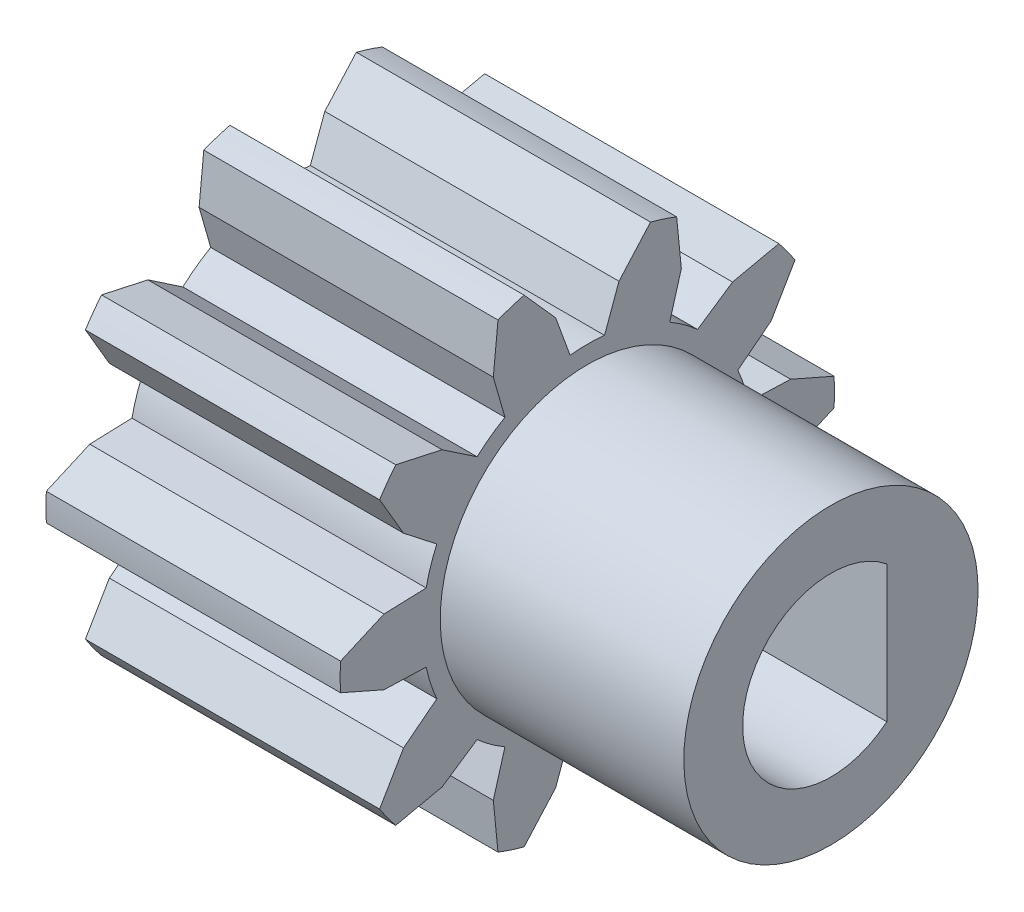
from build123d import *

# Parameters (mm, degrees)
ESQUISSE1_W              = 5
ESQUISSE1_H              = 4.2
ENL_V_MAT_EXTRU_1_DEPTH  = 6
ENL_V_MAT_EXTRU_2_DEPTH  = 6
ENL_V_MAT_EXTRU_3_DEPTH  = 6
ENL_V_MAT_EXTRU_4_DEPTH  = 6
ENL_V_MAT_EXTRU_5_DEPTH  = 6
ENL_V_MAT_EXTRU_6_DEPTH  = 6
ENL_V_MAT_EXTRU_7_DEPTH  = 6
ENL_V_MAT_EXTRU_8_DEPTH  = 6
ENL_V_MAT_EXTRU_9_DEPTH  = 6
ENL_V_MAT_EXTRU_10_DEPTH = 6
ENL_V_MAT_EXTRU_11_DEPTH = 6
ENL_V_MAT_EXTRU_12_DEPTH = 6
ENL_V_MAT_EXTRU_13_DEPTH = 6
ENL_V_MAT_EXTRU_14_DEPTH = 6
ENL_V_MAT_EXTRU_15_DEPTH = 6
ENL_V_MAT_EXTRU_16_DEPTH = 6
ENL_V_MAT_EXTRU_17_DEPTH = 6
ENL_V_MAT_EXTRU_18_DEPTH = 6
ENL_V_MAT_EXTRU_19_DEPTH = 6
ENL_V_MAT_EXTRU_20_DEPTH = 6
ESQUISSE22_W             = 4.14
ESQUISSE22_H             = 2.5
ESQUISSE29_R             = 1.5
ENL_V_MAT_EXTRU_21_DEPTH = 10
BOSS_EXTRU_1_DEPTH       = 9.14


with BuildPart() as part:
    # Esquisse1 → Révolution1 (revolve)
    with BuildSketch(Plane(origin=(0, 0, 0), x_dir=(-1, 0, 0), z_dir=(0, 0, -1))):
        with Locations((0, 2.1)):
            Rectangle(ESQUISSE1_W, ESQUISSE1_H)
    revolve(axis=Axis((2.5, 0, 0), (-1, 0, 0)))

    # Esquisse2 → Enlèv. mat.-Extru.1 (cut, through all)
    with BuildSketch(Plane.ZY.offset(2.5)):
        with BuildLine():
            Line((4.19351351, -0.233333333), (2.714671649, -0.882050288))
            Line((2.714671649, -0.882050288), (3.529773588, -2.276114764))
            ThreePointArc((3.529773588, -2.276114764), (3.994437368, -1.297871376), (4.19351351, -0.233333333))
        make_face()
    extrude(amount=-ENL_V_MAT_EXTRU_1_DEPTH, mode=Mode.SUBTRACT)

    # Esquisse3 → Enlèv. mat.-Extru.2 (cut, through all)
    with BuildSketch(Plane.ZY.offset(2.5)):
        with BuildLine():
            Line((2.557927281, -1.138862601), (3.122928651, -1.58029005))
            Line((3.122928651, -1.58029005), (2.714671649, -0.882050288))
            Line((2.714671649, -0.882050288), (3.455373536, -0.557129899))
            Line((3.455373536, -0.557129899), (2.738813282, -0.582152734))
            ThreePointArc((2.738813282, -0.582152734), (2.662958246, -0.865247584), (2.557927281, -1.138862601))
        make_face()
    extrude(amount=-ENL_V_MAT_EXTRU_2_DEPTH, mode=Mode.SUBTRACT)

    # Esquisse4 → Enlèv. mat.-Extru.3 (cut, through all)
    with BuildSketch(Plane.ZY.offset(2.5)):
        with BuildLine():
            Line((3.255473803, -2.653656028), (1.677759348, -2.309237633))
            Line((1.677759348, -2.309237633), (1.517780128, -3.916164384))
            ThreePointArc((1.517780128, -3.916164384), (2.46869806, -3.397871376), (3.255473803, -2.653656028))
        make_face()
    extrude(amount=-ENL_V_MAT_EXTRU_3_DEPTH, mode=Mode.SUBTRACT)

    # Esquisse5 → Enlèv. mat.-Extru.4 (cut, through all)
    with BuildSketch(Plane.ZY.offset(2.5)):
        with BuildLine():
            Line((1.4, -2.424871131), (1.597631165, -3.114092911))
            Line((1.597631165, -3.114092911), (1.677759348, -2.309237633))
            Line((1.677759348, -2.309237633), (2.467983175, -2.481745162))
            Line((2.467983175, -2.481745162), (1.873565698, -2.080805511))
            ThreePointArc((1.873565698, -2.080805511), (1.645798706, -2.265247584), (1.4, -2.424871131))
        make_face()
    extrude(amount=-ENL_V_MAT_EXTRU_4_DEPTH, mode=Mode.SUBTRACT)

    # Esquisse6 → Enlèv. mat.-Extru.5 (cut, through all)
    with BuildSketch(Plane.ZY.offset(2.5)):
        with BuildLine():
            Line((1.073953753, -4.060372315), (0, -2.85437469))
            Line((0, -2.85437469), (-1.073953753, -4.060372315))
            ThreePointArc((-1.073953753, -4.060372315), (0, -4.2), (1.073953753, -4.060372315))
        make_face()
    extrude(amount=-ENL_V_MAT_EXTRU_5_DEPTH, mode=Mode.SUBTRACT)

    # Esquisse7 → Enlèv. mat.-Extru.6 (cut, through all)
    with BuildSketch(Plane.ZY.offset(2.5)):
        with BuildLine():
            Line((-0.292679697, -2.784661307), (-0.537907124, -3.458418125))
            Line((-0.537907124, -3.458418125), (0, -2.85437469))
            Line((0, -2.85437469), (0.537907124, -3.458418125))
            Line((0.537907124, -3.458418125), (0.292679697, -2.784661307))
            ThreePointArc((0.292679697, -2.784661307), (0, -2.8), (-0.292679697, -2.784661307))
        make_face()
    extrude(amount=-ENL_V_MAT_EXTRU_6_DEPTH, mode=Mode.SUBTRACT)

    # Esquisse8 → Enlèv. mat.-Extru.7 (cut, through all)
    with BuildSketch(Plane.ZY.offset(2.5)):
        with BuildLine():
            Line((-1.517780128, -3.916164384), (-1.677759348, -2.309237633))
            Line((-1.677759348, -2.309237633), (-3.255473803, -2.653656028))
            ThreePointArc((-3.255473803, -2.653656028), (-2.46869806, -3.397871376), (-1.517780128, -3.916164384))
        make_face()
    extrude(amount=-ENL_V_MAT_EXTRU_7_DEPTH, mode=Mode.SUBTRACT)

    # Esquisse9 → Enlèv. mat.-Extru.8 (cut, through all)
    with BuildSketch(Plane.ZY.offset(2.5)):
        with BuildLine():
            Line((-1.873565698, -2.080805511), (-2.467983175, -2.481745162))
            Line((-2.467983175, -2.481745162), (-1.677759348, -2.309237633))
            Line((-1.677759348, -2.309237633), (-1.597631165, -3.114092911))
            Line((-1.597631165, -3.114092911), (-1.4, -2.424871131))
            ThreePointArc((-1.4, -2.424871131), (-1.645798706, -2.265247584), (-1.873565698, -2.080805511))
        make_face()
    extrude(amount=-ENL_V_MAT_EXTRU_8_DEPTH, mode=Mode.SUBTRACT)

    # Esquisse10 → Enlèv. mat.-Extru.9 (cut, through all)
    with BuildSketch(Plane.ZY.offset(2.5)):
        with BuildLine():
            Line((-3.529773588, -2.276114764), (-2.714671649, -0.882050288))
            Line((-2.714671649, -0.882050288), (-4.19351351, -0.233333333))
            ThreePointArc((-4.19351351, -0.233333333), (-3.994437368, -1.297871376), (-3.529773588, -2.276114764))
        make_face()
    extrude(amount=-ENL_V_MAT_EXTRU_9_DEPTH, mode=Mode.SUBTRACT)

    # Esquisse11 → Enlèv. mat.-Extru.10 (cut, through all)
    with BuildSketch(Plane.ZY.offset(2.5)):
        with BuildLine():
            Line((-2.738813282, -0.582152734), (-3.455373536, -0.557129899))
            Line((-3.455373536, -0.557129899), (-2.714671649, -0.882050288))
            Line((-2.714671649, -0.882050288), (-3.122928651, -1.58029005))
            Line((-3.122928651, -1.58029005), (-2.557927281, -1.138862601))
            ThreePointArc((-2.557927281, -1.138862601), (-2.662958246, -0.865247584), (-2.738813282, -0.582152734))
        make_face()
    extrude(amount=-ENL_V_MAT_EXTRU_10_DEPTH, mode=Mode.SUBTRACT)

    # Esquisse12 → Enlèv. mat.-Extru.11 (cut, through all)
    with BuildSketch(Plane.ZY.offset(2.5)):
        with BuildLine():
            Line((-4.19351351, 0.233333333), (-2.714671649, 0.882050288))
            Line((-2.714671649, 0.882050288), (-3.529773588, 2.276114764))
            ThreePointArc((-3.529773588, 2.276114764), (-3.994437368, 1.297871376), (-4.19351351, 0.233333333))
        make_face()
    extrude(amount=-ENL_V_MAT_EXTRU_11_DEPTH, mode=Mode.SUBTRACT)

    # Esquisse13 → Enlèv. mat.-Extru.12 (cut, through all)
    with BuildSketch(Plane.ZY.offset(2.5)):
        with BuildLine():
            Line((-2.714671649, 0.882050288), (-3.455373536, 0.557129899))
            Line((-3.455373536, 0.557129899), (-2.738813282, 0.582152734))
            ThreePointArc((-2.738813282, 0.582152734), (-2.662958246, 0.865247584), (-2.557927281, 1.138862601))
            Line((-2.557927281, 1.138862601), (-3.122928651, 1.58029005))
            Line((-3.122928651, 1.58029005), (-2.714671649, 0.882050288))
        make_face()
    extrude(amount=-ENL_V_MAT_EXTRU_12_DEPTH, mode=Mode.SUBTRACT)

    # Esquisse14 → Enlèv. mat.-Extru.13 (cut, through all)
    with BuildSketch(Plane.ZY.offset(2.5)):
        with BuildLine():
            Line((-3.255473803, 2.653656028), (-1.677759348, 2.309237633))
            Line((-1.677759348, 2.309237633), (-1.517780128, 3.916164384))
            ThreePointArc((-1.517780128, 3.916164384), (-2.46869806, 3.397871376), (-3.255473803, 2.653656028))
        make_face()
    extrude(amount=-ENL_V_MAT_EXTRU_13_DEPTH, mode=Mode.SUBTRACT)

    # Esquisse15 → Enlèv. mat.-Extru.14 (cut, through all)
    with BuildSketch(Plane.ZY.offset(2.5)):
        with BuildLine():
            Line((-1.677759348, 2.309237633), (-2.467983175, 2.481745162))
            Line((-2.467983175, 2.481745162), (-1.873565698, 2.080805511))
            ThreePointArc((-1.873565698, 2.080805511), (-1.645798706, 2.265247584), (-1.4, 2.424871131))
            Line((-1.4, 2.424871131), (-1.597631165, 3.114092911))
            Line((-1.597631165, 3.114092911), (-1.677759348, 2.309237633))
        make_face()
    extrude(amount=-ENL_V_MAT_EXTRU_14_DEPTH, mode=Mode.SUBTRACT)

    # Esquisse16 → Enlèv. mat.-Extru.15 (cut, through all)
    with BuildSketch(Plane.ZY.offset(2.5)):
        with BuildLine():
            Line((-1.073953753, 4.060372315), (0, 2.85437469))
            Line((0, 2.85437469), (1.073953753, 4.060372315))
            ThreePointArc((1.073953753, 4.060372315), (0, 4.2), (-1.073953753, 4.060372315))
        make_face()
    extrude(amount=-ENL_V_MAT_EXTRU_15_DEPTH, mode=Mode.SUBTRACT)

    # Esquisse17 → Enlèv. mat.-Extru.16 (cut, through all)
    with BuildSketch(Plane.ZY.offset(2.5)):
        with BuildLine():
            Line((0, 2.85437469), (-0.537907124, 3.458418125))
            Line((-0.537907124, 3.458418125), (-0.292679697, 2.784661307))
            ThreePointArc((-0.292679697, 2.784661307), (0, 2.8), (0.292679697, 2.784661307))
            Line((0.292679697, 2.784661307), (0.537907124, 3.458418125))
            Line((0.537907124, 3.458418125), (0, 2.85437469))
        make_face()
    extrude(amount=-ENL_V_MAT_EXTRU_16_DEPTH, mode=Mode.SUBTRACT)

    # Esquisse18 → Enlèv. mat.-Extru.17 (cut, through all)
    with BuildSketch(Plane.ZY.offset(2.5)):
        with BuildLine():
            Line((1.517780128, 3.916164384), (1.677759348, 2.309237633))
            Line((1.677759348, 2.309237633), (3.255473803, 2.653656028))
            ThreePointArc((3.255473803, 2.653656028), (2.46869806, 3.397871376), (1.517780128, 3.916164384))
        make_face()
    extrude(amount=-ENL_V_MAT_EXTRU_17_DEPTH, mode=Mode.SUBTRACT)

    # Esquisse19 → Enlèv. mat.-Extru.18 (cut, through all)
    with BuildSketch(Plane.ZY.offset(2.5)):
        with BuildLine():
            Line((1.677759348, 2.309237633), (1.597631165, 3.114092911))
            Line((1.597631165, 3.114092911), (1.4, 2.424871131))
            ThreePointArc((1.4, 2.424871131), (1.645798706, 2.265247584), (1.873565698, 2.080805511))
            Line((1.873565698, 2.080805511), (2.467983175, 2.481745162))
            Line((2.467983175, 2.481745162), (1.677759348, 2.309237633))
        make_face()
    extrude(amount=-ENL_V_MAT_EXTRU_18_DEPTH, mode=Mode.SUBTRACT)

    # Esquisse20 → Enlèv. mat.-Extru.19 (cut, through all)
    with BuildSketch(Plane.ZY.offset(2.5)):
        with BuildLine():
            Line((3.529773588, 2.276114764), (2.714671649, 0.882050288))
            Line((2.714671649, 0.882050288), (4.19351351, 0.233333333))
            ThreePointArc((4.19351351, 0.233333333), (3.994437368, 1.297871376), (3.529773588, 2.276114764))
        make_face()
    extrude(amount=-ENL_V_MAT_EXTRU_19_DEPTH, mode=Mode.SUBTRACT)

    # Esquisse21 → Enlèv. mat.-Extru.20 (cut, through all)
    with BuildSketch(Plane.ZY.offset(2.5)):
        with BuildLine():
            Line((2.714671649, 0.882050288), (3.122928651, 1.58029005))
            Line((3.122928651, 1.58029005), (2.557927281, 1.138862601))
            ThreePointArc((2.557927281, 1.138862601), (2.662958246, 0.865247584), (2.738813282, 0.582152734))
            Line((2.738813282, 0.582152734), (3.455373536, 0.557129899))
            Line((3.455373536, 0.557129899), (2.714671649, 0.882050288))
        make_face()
    extrude(amount=-ENL_V_MAT_EXTRU_20_DEPTH, mode=Mode.SUBTRACT)

    # Esquisse22 → Révolution2 (revolve)
    with BuildSketch(Plane(origin=(0, 0, 0), x_dir=(-1, 0, 0), z_dir=(0, 0, -1))):
        with Locations((-4.57, 1.25)):
            Rectangle(ESQUISSE22_W, ESQUISSE22_H)
    revolve(axis=Axis((6.64, 0, 0), (-1, 0, 0)))

    # Esquisse29 → Enlèv. mat.-Extru.21 (cut)
    with BuildSketch(Plane.ZY.offset(2.5)):
        Circle(ESQUISSE29_R)
    extrude(amount=-ENL_V_MAT_EXTRU_21_DEPTH, mode=Mode.SUBTRACT)

    # Esquisse31 → Boss.-Extru.1 (add)
    with BuildSketch(Plane.ZY.offset(2.5)):
        with BuildLine():
            Line((-0.95, 0), (-0.95, 1.160818677))
            ThreePointArc((-0.95, 1.160818677), (-1.5, 0), (-0.95, -1.160818677))
            Line((-0.95, -1.160818677), (-0.95, 0))
        make_face()
    extrude(amount=-BOSS_EXTRU_1_DEPTH)


solid = part.part
